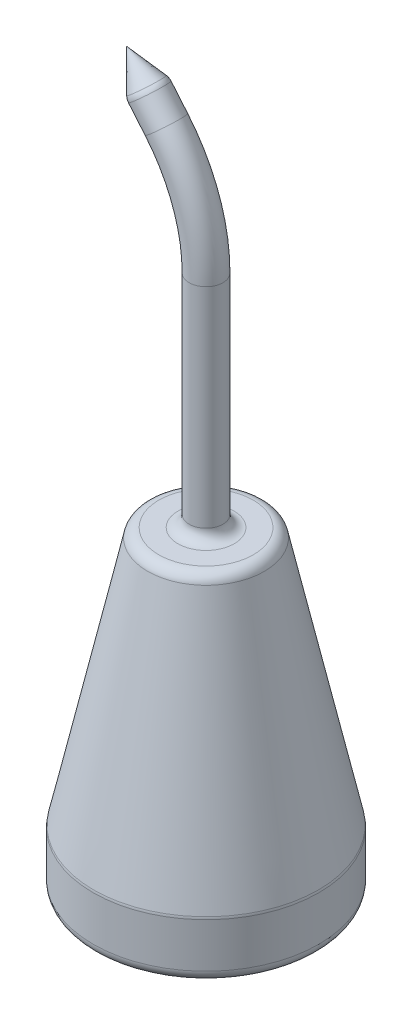
from build123d import *

# Parameters (mm, degrees)
SKETCH4_R = 3
FILLET1_R = 2


with BuildPart() as part:
    # Sketch1 → Revolve1 (revolve)
    with BuildSketch(Plane.XY):
        Polygon((10, 0), (20, 0), (20, 10.125), (10, 56), (0, 56), (0, 30), (10, 30), align=None)
    revolve(axis=Axis((0, 42, 0), (0, -1, 0)))

    # Sweep1: sweep along a path in Sketch2
    with BuildLine(Plane.XY) as sweep1_path:
        Line((0, 56), (0, 95.080892972))
        ThreePointArc((0, 95.080892972), (-1.809221376, 105.341497272), (-7.018666706, 114.364521263))
        Line((-7.018666706, 114.364521263), (-10.284601755, 118.25671109))
    # Sketch4 → Sweep1 (sweep)
    with BuildSketch(Plane(origin=(0, 56, 0), x_dir=(1, 0, 0), z_dir=(0, 1, 0))):
        Circle(SKETCH4_R)
    sweep(path=sweep1_path.line)

    # Sketch3 → Revolve2 (revolve)
    with BuildSketch(Plane.XY):
        Polygon((-10.284601755, 118.25671109), (-7.986468426, 120.185073919), (-14.141327413, 122.852977749), align=None)
    revolve(axis=Axis((-14.141327413, 122.852977749, 0), (0.64278761, -0.766044443, 0)))

    # Fillet1
    fillet1_edges = [part.edges().sort_by_distance(p)[0] for p in [
        (-3, 56, 0),
        (-12.582735084, 116.328348261, 0),
        (-10, 56, 0),
        (-20, 10.125, 0),
        (-20, 0, 0),
    ]]
    fillet(fillet1_edges, radius=FILLET1_R)


solid = part.part
